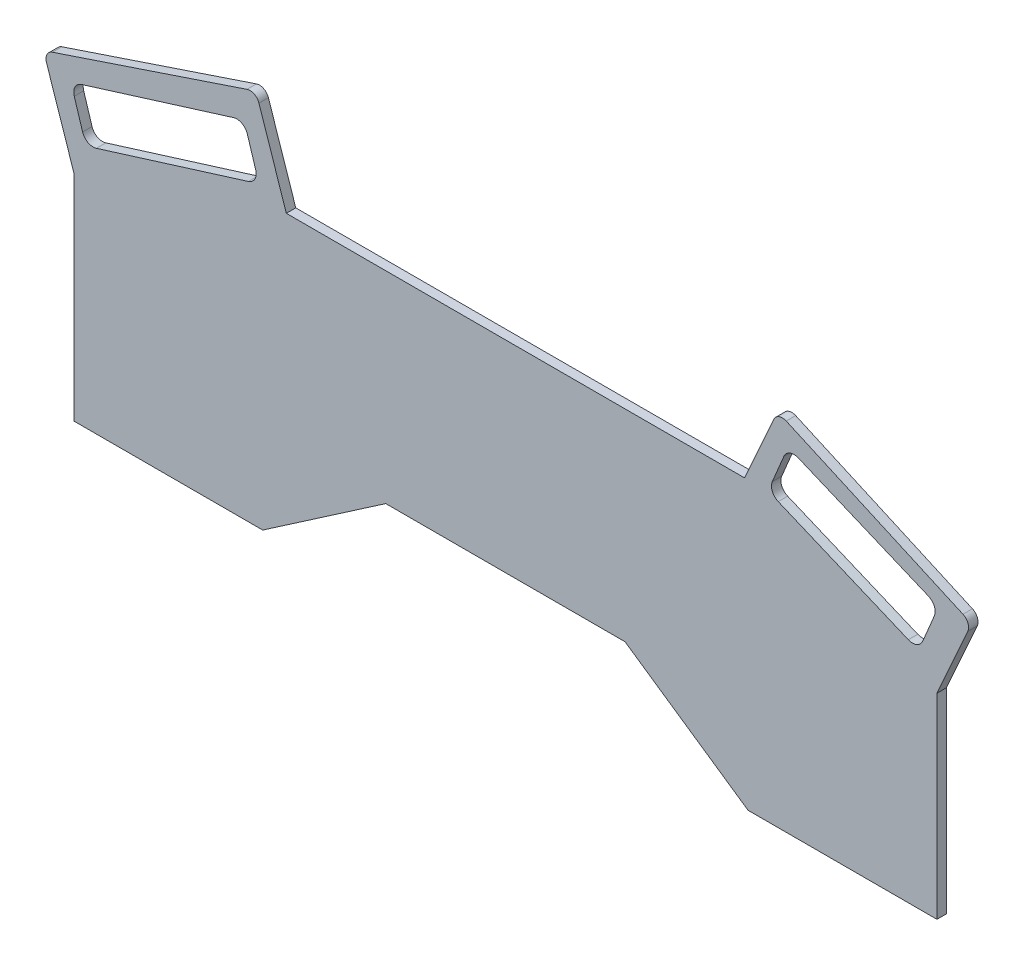
from build123d import *

# Parameters (mm, degrees)
BOSS_EXTRUDE1_DEPTH = 10
CUT_EXTRUDE1_DEPTH  = 10
CUT_EXTRUDE2_DEPTH  = 10


with BuildPart() as part:
    # Sketch2 → Boss-Extrude1 (new body)
    with BuildSketch(Plane.XY):
        with BuildLine():
            Line((-257, -160), (-126.694416638, -70.567832456))
            Line((-126.694416638, -70.567832456), (126.694416638, -70.567832456))
            Line((126.694416638, -70.567832456), (257, -160))
            Line((257, -160), (457, -160))
            Line((457, -160), (457, 47.365686012))
            Line((457, 47.365686012), (489.618964007, 120.413637298))
            ThreePointArc((489.618964007, 120.413637298), (489.82769414, 128.064459181), (484.565340597, 133.622001709))
            Line((484.565340597, 133.622001709), (297.41734098, 217.19140723))
            ThreePointArc((297.41734098, 217.19140723), (289.766519097, 217.400137363), (284.208976569, 212.13778382))
            Line((284.208976569, 212.13778382), (253.339865194, 143.008508485))
            Line((253.339865194, 143.008508485), (-232, 143.008508485))
            Line((-232, 143.008508485), (-260.982148435, 229.584058556))
            ThreePointArc((-260.982148435, 229.584058556), (-266.004269265, 235.359605814), (-273.639373591, 235.892358751))
            Line((-273.639373591, 235.892358751), (-479.673848241, 166.919978879))
            ThreePointArc((-479.673848241, 166.919978879), (-485.449395499, 161.897858049), (-485.982148435, 154.262753723))
            Line((-485.982148435, 154.262753723), (-457, 67.687203652))
            Line((-457, 67.687203652), (-457, -160))
            Line((-457, -160), (-257, -160))
        make_face()
    extrude(amount=BOSS_EXTRUDE1_DEPTH)

    # Sketch3 → Cut-Extrude1 (cut)
    with BuildSketch(Plane.XY.offset(10)):
        with BuildLine():
            Line((-456.568069909, 138.128067643), (-447.737597005, 109.744404736))
            ThreePointArc((-447.737597005, 109.744404736), (-442.025570712, 102.884114481), (-433.135600426, 102.072169246))
            Line((-433.135600426, 102.072169246), (-272.142751839, 152.15883325))
            ThreePointArc((-272.142751839, 152.15883325), (-265.282461584, 157.870859543), (-264.470516349, 166.760829829))
            Line((-264.470516349, 166.760829829), (-273.300989253, 195.144492736))
            ThreePointArc((-273.300989253, 195.144492736), (-279.013015546, 202.004782992), (-287.902985832, 202.816728227))
            Line((-287.902985832, 202.816728227), (-448.895834419, 152.730064222))
            ThreePointArc((-448.895834419, 152.730064222), (-455.756124674, 147.01803793), (-456.568069909, 138.128067643))
        make_face()
    extrude(amount=-CUT_EXTRUDE1_DEPTH, mode=Mode.SUBTRACT)

    # Sketch4 → Cut-Extrude2 (cut)
    with BuildSketch(Plane.XY.offset(10)):
        with BuildLine():
            Line((294.889717658, 183.505126769), (282.667716754, 154.360355381))
            ThreePointArc((282.667716754, 154.360355381), (282.628613497, 145.433469155), (288.913225104, 139.093557192))
            Line((288.913225104, 139.093557192), (426.679323763, 81.320677109))
            ThreePointArc((426.679323763, 81.320677109), (435.606209989, 81.281573852), (441.946121952, 87.566185459))
            Line((441.946121952, 87.566185459), (454.168122857, 116.710956847))
            ThreePointArc((454.168122857, 116.710956847), (454.207226114, 125.637843073), (447.922614507, 131.977755036))
            Line((447.922614507, 131.977755036), (310.156515848, 189.750635119))
            ThreePointArc((310.156515848, 189.750635119), (301.229629622, 189.789738376), (294.889717658, 183.505126769))
        make_face()
    extrude(amount=-CUT_EXTRUDE2_DEPTH, mode=Mode.SUBTRACT)


solid = part.part
